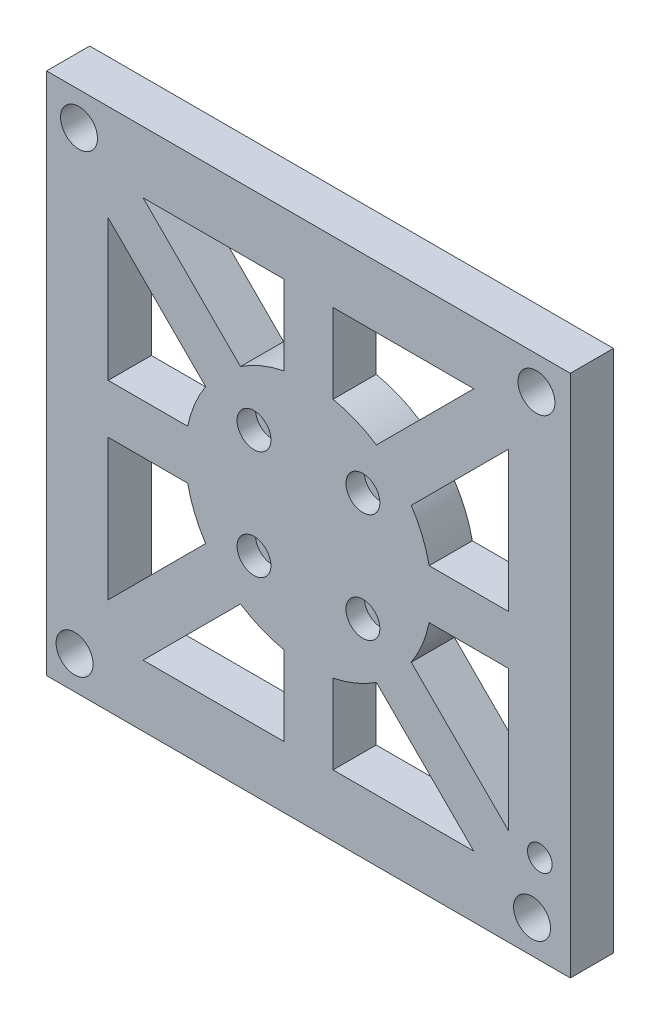
from build123d import *

# Parameters (mm, degrees)
CROQUIS1_W              = 85
CROQUIS1_H              = 85
CROQUIS1_R              = 2.9
CROQUIS1_R_2            = 1.35
SALIENTE_EXTRUIR1_DEPTH = 5
CROQUIS3_R              = 2.75
CORTAR_EXTRUIR2_DEPTH   = 1
CROQUIS4_R              = 2
CORTAR_EXTRUIR3_DEPTH   = 142.742888627
CROQUIS5_R              = 3
CORTAR_EXTRUIR4_DEPTH   = 142.742888627
CROQUIS6_W              = 85
CROQUIS6_H              = 85
CROQUIS6_R              = 2.75
CROQUIS6_R_2            = 3
CROQUIS6_R_3            = 2
SALIENTE_EXTRUIR2_DEPTH = 2


with BuildPart() as part:
    # Croquis1 → Saliente-Extruir1 (new body)
    with BuildSketch(Plane.XY.offset(1012.9)):
        with Locations((-72.207592574, 40.615670498)):
            Rectangle(CROQUIS1_W, CROQUIS1_H)
        with BuildLine():
            Line((-99.050738324, 73.115670498), (-76.207592574, 73.115670498))
            Line((-76.207592574, 73.115670498), (-76.207592574, 60.21158844))
            ThreePointArc((-76.207592574, 60.21158844), (-72.207592574, 60.615670498), (-68.207592574, 60.21158844))
            Line((-68.207592574, 60.21158844), (-68.207592574, 73.115670498))
            Line((-68.207592574, 73.115670498), (-45.364446823, 73.115670498))
            Line((-45.364446823, 73.115670498), (-61.179613238, 57.300504083))
            ThreePointArc((-61.179613238, 57.300504083), (-58.06545695, 54.757806122), (-55.522758989, 51.643649834))
            Line((-55.522758989, 51.643649834), (-39.707592574, 67.458816249))
            Line((-39.707592574, 67.458816249), (-39.707592574, 44.615670498))
            Line((-39.707592574, 44.615670498), (-52.611674632, 44.615670498))
            ThreePointArc((-52.611674632, 44.615670498), (-52.859983028, 45.682227995), (-53.166295653, 46.733595929))
            Line((-53.166295653, 46.733595929), (-58.538384228, 46.733595929))
            ThreePointArc((-58.538384228, 46.733595929), (-59.599044399, 46.294256101), (-60.038384228, 45.233595929))
            Line((-60.038384228, 45.233595929), (-60.038384228, 35.997745067))
            ThreePointArc((-60.038384228, 35.997745067), (-59.599044399, 34.937084896), (-58.538384228, 34.497745067))
            Line((-58.538384228, 34.497745067), (-53.166295653, 34.497745067))
            ThreePointArc((-53.166295653, 34.497745067), (-52.859983028, 35.549113001), (-52.611674632, 36.615670498))
            Line((-52.611674632, 36.615670498), (-39.707592574, 36.615670498))
            Line((-39.707592574, 36.615670498), (-39.707592574, 13.772524748))
            Line((-39.707592574, 13.772524748), (-55.522758989, 29.587691162))
            ThreePointArc((-55.522758989, 29.587691162), (-58.06545695, 26.473534874), (-61.179613238, 23.930836913))
            Line((-61.179613238, 23.930836913), (-45.364446823, 8.115670498))
            Line((-45.364446823, 8.115670498), (-68.207592574, 8.115670498))
            Line((-68.207592574, 8.115670498), (-68.207592574, 21.019752556))
            ThreePointArc((-68.207592574, 21.019752556), (-72.207592574, 20.615670498), (-76.207592574, 21.019752556))
            Line((-76.207592574, 21.019752556), (-76.207592574, 8.115670498))
            Line((-76.207592574, 8.115670498), (-99.050738324, 8.115670498))
            Line((-99.050738324, 8.115670498), (-83.23557191, 23.930836913))
            ThreePointArc((-83.23557191, 23.930836913), (-86.349728198, 26.473534874), (-88.892426159, 29.587691162))
            Line((-88.892426159, 29.587691162), (-104.707592574, 13.772524748))
            Line((-104.707592574, 13.772524748), (-104.707592574, 36.615670498))
            Line((-104.707592574, 36.615670498), (-91.803510516, 36.615670498))
            ThreePointArc((-91.803510516, 36.615670498), (-92.207592574, 40.615670498), (-91.803510516, 44.615670498))
            Line((-91.803510516, 44.615670498), (-104.707592574, 44.615670498))
            Line((-104.707592574, 44.615670498), (-104.707592574, 67.458816249))
            Line((-104.707592574, 67.458816249), (-88.892426159, 51.643649834))
            ThreePointArc((-88.892426159, 51.643649834), (-86.349728198, 54.757806122), (-83.23557191, 57.300504083))
            Line((-83.23557191, 57.300504083), (-99.050738324, 73.115670498))
        make_face(mode=Mode.SUBTRACT)
        with BuildLine():
            ThreePointArc((-68.207592574, 60.21158844), (-72.207592574, 60.615670498), (-76.207592574, 60.21158844))
            ThreePointArc((-76.207592574, 60.21158844), (-79.861261221, 59.093261148), (-83.23557191, 57.300504083))
            ThreePointArc((-83.23557191, 57.300504083), (-86.349728198, 54.757806122), (-88.892426159, 51.643649834))
            ThreePointArc((-88.892426159, 51.643649834), (-90.685183224, 48.269339145), (-91.803510516, 44.615670498))
            ThreePointArc((-91.803510516, 44.615670498), (-92.207592574, 40.615670498), (-91.803510516, 36.615670498))
            ThreePointArc((-91.803510516, 36.615670498), (-90.685183224, 32.962001851), (-88.892426159, 29.587691162))
            ThreePointArc((-88.892426159, 29.587691162), (-86.349728198, 26.473534874), (-83.23557191, 23.930836913))
            ThreePointArc((-83.23557191, 23.930836913), (-79.861261221, 22.138079848), (-76.207592574, 21.019752556))
            ThreePointArc((-76.207592574, 21.019752556), (-72.207592574, 20.615670498), (-68.207592574, 21.019752556))
            ThreePointArc((-68.207592574, 21.019752556), (-64.553923927, 22.138079848), (-61.179613238, 23.930836913))
            ThreePointArc((-61.179613238, 23.930836913), (-58.06545695, 26.473534874), (-55.522758989, 29.587691162))
            ThreePointArc((-55.522758989, 29.587691162), (-54.17661208, 31.962131197), (-53.166295653, 34.497745067))
            Line((-53.166295653, 34.497745067), (-58.538384228, 34.497745067))
            ThreePointArc((-58.538384228, 34.497745067), (-59.599044399, 34.937084896), (-60.038384228, 35.997745067))
            Line((-60.038384228, 35.997745067), (-60.038384228, 45.233595929))
            ThreePointArc((-60.038384228, 45.233595929), (-59.599044399, 46.294256101), (-58.538384228, 46.733595929))
            Line((-58.538384228, 46.733595929), (-53.166295653, 46.733595929))
            ThreePointArc((-53.166295653, 46.733595929), (-54.17661208, 49.269209799), (-55.522758989, 51.643649834))
            ThreePointArc((-55.522758989, 51.643649834), (-58.06545695, 54.757806122), (-61.179613238, 57.300504083))
            ThreePointArc((-61.179613238, 57.300504083), (-64.553923927, 59.093261148), (-68.207592574, 60.21158844))
        make_face()
        with Locations((-84.228407854, 28.594855218)):
            Circle(CROQUIS1_R, mode=Mode.SUBTRACT)
        with Locations((-81.046427339, 31.776835733)):
            Circle(CROQUIS1_R_2, mode=Mode.SUBTRACT)
        with Locations((-60.186777294, 28.594855218)):
            Circle(CROQUIS1_R, mode=Mode.SUBTRACT)
        with Locations((-63.368757809, 31.776835733)):
            Circle(CROQUIS1_R_2, mode=Mode.SUBTRACT)
        with Locations((-81.046427339, 49.454505263)):
            Circle(CROQUIS1_R_2, mode=Mode.SUBTRACT)
        with Locations((-84.228407854, 52.636485778)):
            Circle(CROQUIS1_R, mode=Mode.SUBTRACT)
        with Locations((-63.368757809, 49.454505263)):
            Circle(CROQUIS1_R_2, mode=Mode.SUBTRACT)
        with Locations((-60.186777294, 52.636485778)):
            Circle(CROQUIS1_R, mode=Mode.SUBTRACT)
        with BuildLine():
            ThreePointArc((-68.207592574, 60.21158844), (-72.207592574, 60.615670498), (-76.207592574, 60.21158844))
            ThreePointArc((-76.207592574, 60.21158844), (-79.861261221, 59.093261148), (-83.23557191, 57.300504083))
            ThreePointArc((-83.23557191, 57.300504083), (-86.349728198, 54.757806122), (-88.892426159, 51.643649834))
            ThreePointArc((-88.892426159, 51.643649834), (-90.685183224, 48.269339145), (-91.803510516, 44.615670498))
            ThreePointArc((-91.803510516, 44.615670498), (-92.207592574, 40.615670498), (-91.803510516, 36.615670498))
            ThreePointArc((-91.803510516, 36.615670498), (-90.685183224, 32.962001851), (-88.892426159, 29.587691162))
            ThreePointArc((-88.892426159, 29.587691162), (-86.349728198, 26.473534874), (-83.23557191, 23.930836913))
            ThreePointArc((-83.23557191, 23.930836913), (-79.861261221, 22.138079848), (-76.207592574, 21.019752556))
            ThreePointArc((-76.207592574, 21.019752556), (-72.207592574, 20.615670498), (-68.207592574, 21.019752556))
            ThreePointArc((-68.207592574, 21.019752556), (-64.553923927, 22.138079848), (-61.179613238, 23.930836913))
            ThreePointArc((-61.179613238, 23.930836913), (-58.06545695, 26.473534874), (-55.522758989, 29.587691162))
            ThreePointArc((-55.522758989, 29.587691162), (-54.17661208, 31.962131197), (-53.166295653, 34.497745067))
            Line((-53.166295653, 34.497745067), (-58.538384228, 34.497745067))
            ThreePointArc((-58.538384228, 34.497745067), (-59.599044399, 34.937084896), (-60.038384228, 35.997745067))
            Line((-60.038384228, 35.997745067), (-60.038384228, 45.233595929))
            ThreePointArc((-60.038384228, 45.233595929), (-59.599044399, 46.294256101), (-58.538384228, 46.733595929))
            Line((-58.538384228, 46.733595929), (-53.166295653, 46.733595929))
            ThreePointArc((-53.166295653, 46.733595929), (-54.17661208, 49.269209799), (-55.522758989, 51.643649834))
            ThreePointArc((-55.522758989, 51.643649834), (-58.06545695, 54.757806122), (-61.179613238, 57.300504083))
            ThreePointArc((-61.179613238, 57.300504083), (-64.553923927, 59.093261148), (-68.207592574, 60.21158844))
        make_face()
        with Locations((-84.228407854, 28.594855218)):
            Circle(CROQUIS1_R, mode=Mode.SUBTRACT)
        with Locations((-81.046427339, 31.776835733)):
            Circle(CROQUIS1_R_2, mode=Mode.SUBTRACT)
        with Locations((-60.186777294, 28.594855218)):
            Circle(CROQUIS1_R, mode=Mode.SUBTRACT)
        with Locations((-63.368757809, 31.776835733)):
            Circle(CROQUIS1_R_2, mode=Mode.SUBTRACT)
        with Locations((-81.046427339, 49.454505263)):
            Circle(CROQUIS1_R_2, mode=Mode.SUBTRACT)
        with Locations((-84.228407854, 52.636485778)):
            Circle(CROQUIS1_R, mode=Mode.SUBTRACT)
        with Locations((-63.368757809, 49.454505263)):
            Circle(CROQUIS1_R_2, mode=Mode.SUBTRACT)
        with Locations((-60.186777294, 52.636485778)):
            Circle(CROQUIS1_R, mode=Mode.SUBTRACT)
        with BuildLine():
            ThreePointArc((-68.207592574, 60.21158844), (-72.207592574, 60.615670498), (-76.207592574, 60.21158844))
            ThreePointArc((-76.207592574, 60.21158844), (-79.861261221, 59.093261148), (-83.23557191, 57.300504083))
            ThreePointArc((-83.23557191, 57.300504083), (-86.349728198, 54.757806122), (-88.892426159, 51.643649834))
            ThreePointArc((-88.892426159, 51.643649834), (-90.685183224, 48.269339145), (-91.803510516, 44.615670498))
            ThreePointArc((-91.803510516, 44.615670498), (-92.207592574, 40.615670498), (-91.803510516, 36.615670498))
            ThreePointArc((-91.803510516, 36.615670498), (-90.685183224, 32.962001851), (-88.892426159, 29.587691162))
            ThreePointArc((-88.892426159, 29.587691162), (-86.349728198, 26.473534874), (-83.23557191, 23.930836913))
            ThreePointArc((-83.23557191, 23.930836913), (-79.861261221, 22.138079848), (-76.207592574, 21.019752556))
            ThreePointArc((-76.207592574, 21.019752556), (-72.207592574, 20.615670498), (-68.207592574, 21.019752556))
            ThreePointArc((-68.207592574, 21.019752556), (-64.553923927, 22.138079848), (-61.179613238, 23.930836913))
            ThreePointArc((-61.179613238, 23.930836913), (-58.06545695, 26.473534874), (-55.522758989, 29.587691162))
            ThreePointArc((-55.522758989, 29.587691162), (-54.17661208, 31.962131197), (-53.166295653, 34.497745067))
            Line((-53.166295653, 34.497745067), (-58.538384228, 34.497745067))
            ThreePointArc((-58.538384228, 34.497745067), (-59.599044399, 34.937084896), (-60.038384228, 35.997745067))
            Line((-60.038384228, 35.997745067), (-60.038384228, 45.233595929))
            ThreePointArc((-60.038384228, 45.233595929), (-59.599044399, 46.294256101), (-58.538384228, 46.733595929))
            Line((-58.538384228, 46.733595929), (-53.166295653, 46.733595929))
            ThreePointArc((-53.166295653, 46.733595929), (-54.17661208, 49.269209799), (-55.522758989, 51.643649834))
            ThreePointArc((-55.522758989, 51.643649834), (-58.06545695, 54.757806122), (-61.179613238, 57.300504083))
            ThreePointArc((-61.179613238, 57.300504083), (-64.553923927, 59.093261148), (-68.207592574, 60.21158844))
        make_face()
        with Locations((-84.228407854, 28.594855218)):
            Circle(CROQUIS1_R, mode=Mode.SUBTRACT)
        with Locations((-81.046427339, 31.776835733)):
            Circle(CROQUIS1_R_2, mode=Mode.SUBTRACT)
        with Locations((-60.186777294, 28.594855218)):
            Circle(CROQUIS1_R, mode=Mode.SUBTRACT)
        with Locations((-63.368757809, 31.776835733)):
            Circle(CROQUIS1_R_2, mode=Mode.SUBTRACT)
        with Locations((-81.046427339, 49.454505263)):
            Circle(CROQUIS1_R_2, mode=Mode.SUBTRACT)
        with Locations((-84.228407854, 52.636485778)):
            Circle(CROQUIS1_R, mode=Mode.SUBTRACT)
        with Locations((-63.368757809, 49.454505263)):
            Circle(CROQUIS1_R_2, mode=Mode.SUBTRACT)
        with Locations((-60.186777294, 52.636485778)):
            Circle(CROQUIS1_R, mode=Mode.SUBTRACT)
        with Locations((-60.186777294, 28.594855218)):
            Circle(CROQUIS1_R)
        with Locations((-84.228407854, 28.594855218)):
            Circle(CROQUIS1_R)
        with Locations((-84.228407854, 52.636485778)):
            Circle(CROQUIS1_R)
        with Locations((-60.186777294, 52.636485778)):
            Circle(CROQUIS1_R)
    extrude(amount=SALIENTE_EXTRUIR1_DEPTH)

    # Croquis3 → Cortar-Extruir2 (cut)
    with BuildSketch(Plane.XY.offset(1017.9)):
        with Locations((-81.046427339, 49.454505263)):
            Circle(CROQUIS3_R)
        with Locations((-63.368757809, 49.454505263)):
            Circle(CROQUIS3_R)
        with Locations((-81.046427339, 31.776835733)):
            Circle(CROQUIS3_R)
        with Locations((-63.368757809, 31.776835733)):
            Circle(CROQUIS3_R)
    extrude(amount=-CORTAR_EXTRUIR2_DEPTH, mode=Mode.SUBTRACT)

    # Croquis4 → Cortar-Extruir3 (cut, through all)
    with BuildSketch(Plane.XY.offset(1017.9)):
        with Locations((-34.653737572, 12.550194214)):
            Circle(CROQUIS4_R)
    extrude(amount=-CORTAR_EXTRUIR3_DEPTH, mode=Mode.SUBTRACT)

    # Croquis5 → Cortar-Extruir4 (cut, through all)
    with BuildSketch(Plane(origin=(0, 0, 1012.9), x_dir=(-1, 0, 0), z_dir=(0, 0, -1))):
        with Locations((109.449111254, 77.739344608)):
            Circle(CROQUIS5_R)
        with Locations((35.202908474, 77.739344608)):
            Circle(CROQUIS5_R)
        with Locations((35.913375234, 3.496541218)):
            Circle(CROQUIS5_R)
        with Locations((110.159578014, 3.496541218)):
            Circle(CROQUIS5_R)
    extrude(amount=-CORTAR_EXTRUIR4_DEPTH, mode=Mode.SUBTRACT)

    # Croquis6 → Saliente-Extruir2 (add)
    with BuildSketch(Plane.XY.offset(1017.9)):
        with Locations((-72.207592574, 40.615670498)):
            Rectangle(CROQUIS6_W, CROQUIS6_H)
        with Locations((-81.046427339, 49.454505263)):
            Circle(CROQUIS6_R, mode=Mode.SUBTRACT)
        with Locations((-63.368757809, 49.454505263)):
            Circle(CROQUIS6_R, mode=Mode.SUBTRACT)
        with Locations((-63.368757809, 31.776835733)):
            Circle(CROQUIS6_R, mode=Mode.SUBTRACT)
        with Locations((-81.046427339, 31.776835733)):
            Circle(CROQUIS6_R, mode=Mode.SUBTRACT)
        with Locations(Location((-110.159578014, 3.496541218, 0), (0, 0, 180))):
            Circle(CROQUIS6_R_2, mode=Mode.SUBTRACT)
        with Locations(Location((-35.913375234, 3.496541218, 0), (0, 0, 180))):
            Circle(CROQUIS6_R_2, mode=Mode.SUBTRACT)
        with Locations(Location((-35.202908474, 77.739344608, 0), (0, 0, 180))):
            Circle(CROQUIS6_R_2, mode=Mode.SUBTRACT)
        with Locations(Location((-109.449111254, 77.739344608, 0), (0, 0, 180))):
            Circle(CROQUIS6_R_2, mode=Mode.SUBTRACT)
        with Locations((-34.653737572, 12.550194214)):
            Circle(CROQUIS6_R_3, mode=Mode.SUBTRACT)
        with BuildLine():
            Line((-104.707592574, 44.615670498), (-104.707592574, 67.458816249))
            Line((-104.707592574, 67.458816249), (-88.892426159, 51.643649834))
            ThreePointArc((-88.892426159, 51.643649834), (-90.685183224, 48.269339145), (-91.803510516, 44.615670498))
            Line((-91.803510516, 44.615670498), (-104.707592574, 44.615670498))
        make_face(mode=Mode.SUBTRACT)
        with BuildLine():
            Line((-99.050738324, 8.115670498), (-76.207592574, 8.115670498))
            Line((-76.207592574, 8.115670498), (-76.207592574, 21.019752556))
            ThreePointArc((-76.207592574, 21.019752556), (-79.861261221, 22.138079848), (-83.23557191, 23.930836913))
            Line((-83.23557191, 23.930836913), (-99.050738324, 8.115670498))
        make_face(mode=Mode.SUBTRACT)
        with BuildLine():
            Line((-104.707592574, 13.772524748), (-104.707592574, 36.615670498))
            Line((-104.707592574, 36.615670498), (-91.803510516, 36.615670498))
            ThreePointArc((-91.803510516, 36.615670498), (-90.685183224, 32.962001851), (-88.892426159, 29.587691162))
            Line((-88.892426159, 29.587691162), (-104.707592574, 13.772524748))
        make_face(mode=Mode.SUBTRACT)
        with BuildLine():
            Line((-99.050738324, 73.115670498), (-76.207592574, 73.115670498))
            Line((-76.207592574, 73.115670498), (-76.207592574, 60.21158844))
            ThreePointArc((-76.207592574, 60.21158844), (-79.861261221, 59.093261148), (-83.23557191, 57.300504083))
            Line((-83.23557191, 57.300504083), (-99.050738324, 73.115670498))
        make_face(mode=Mode.SUBTRACT)
        with BuildLine():
            Line((-39.707592574, 13.772524748), (-39.707592574, 36.615670498))
            Line((-39.707592574, 36.615670498), (-52.611674632, 36.615670498))
            ThreePointArc((-52.611674632, 36.615670498), (-53.730001924, 32.962001851), (-55.522758989, 29.587691162))
            Line((-55.522758989, 29.587691162), (-39.707592574, 13.772524748))
        make_face(mode=Mode.SUBTRACT)
        with BuildLine():
            Line((-39.707592574, 44.615670498), (-39.707592574, 67.458816249))
            Line((-39.707592574, 67.458816249), (-55.522758989, 51.643649834))
            ThreePointArc((-55.522758989, 51.643649834), (-53.730001924, 48.269339145), (-52.611674632, 44.615670498))
            Line((-52.611674632, 44.615670498), (-39.707592574, 44.615670498))
        make_face(mode=Mode.SUBTRACT)
        with BuildLine():
            Line((-68.207592574, 8.115670498), (-45.364446823, 8.115670498))
            Line((-45.364446823, 8.115670498), (-61.179613238, 23.930836913))
            ThreePointArc((-61.179613238, 23.930836913), (-64.553923927, 22.138079848), (-68.207592574, 21.019752556))
            Line((-68.207592574, 21.019752556), (-68.207592574, 8.115670498))
        make_face(mode=Mode.SUBTRACT)
        with BuildLine():
            Line((-68.207592574, 73.115670498), (-45.364446823, 73.115670498))
            Line((-45.364446823, 73.115670498), (-61.179613238, 57.300504083))
            ThreePointArc((-61.179613238, 57.300504083), (-64.553923927, 59.093261148), (-68.207592574, 60.21158844))
            Line((-68.207592574, 60.21158844), (-68.207592574, 73.115670498))
        make_face(mode=Mode.SUBTRACT)
    extrude(amount=SALIENTE_EXTRUIR2_DEPTH)


solid = part.part
